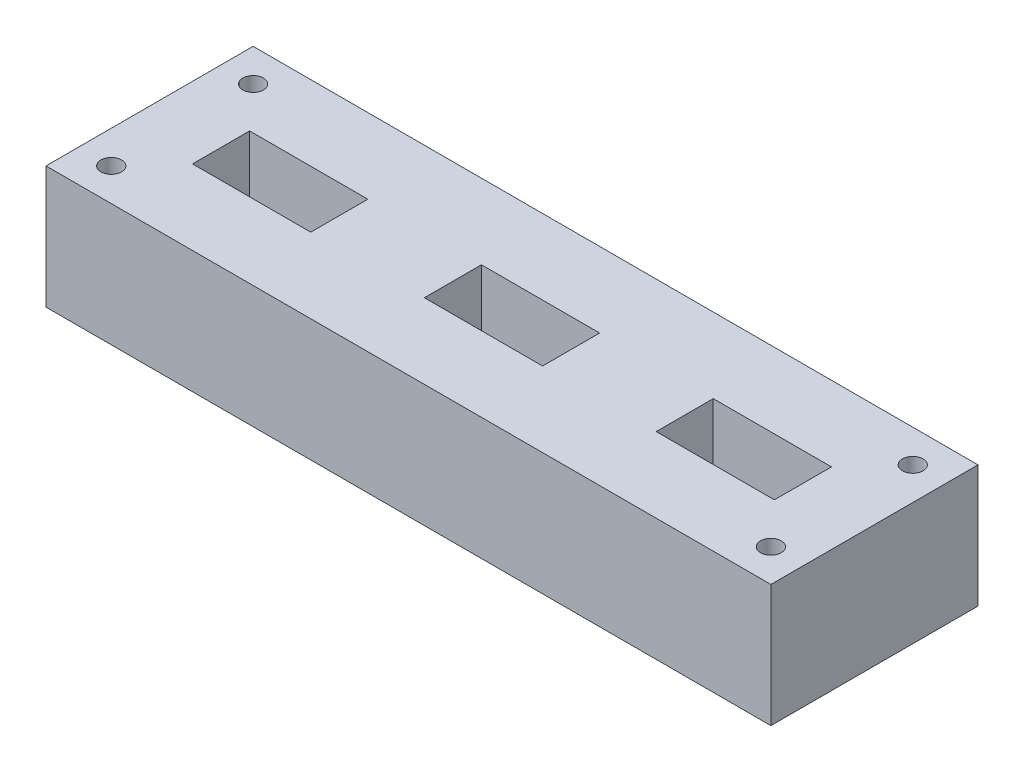
from build123d import *

# Parameters (mm, degrees)
SKETCH1_W           = 88.9
SKETCH1_H           = 25.4
BOSS_EXTRUDE1_DEPTH = 14.999999972
SKETCH2_W           = 14.499999956
SKETCH2_H           = 6.99999997
CUT_EXTRUDE1_DEPTH  = 25.4
SKETCH3_R           = 1.27
CUT_EXTRUDE3_DEPTH  = 25.4


with BuildPart() as part:
    # Sketch1 → Boss-Extrude1 (new body)
    with BuildSketch(Plane(origin=(0, 0, 0), x_dir=(1, 0, 0), z_dir=(0, 1, 0))):
        Rectangle(SKETCH1_W, SKETCH1_H)
    extrude(amount=BOSS_EXTRUDE1_DEPTH)

    # Sketch2 → Cut-Extrude1 (cut)
    with BuildSketch(Plane(origin=(0, 14.999999972, 0), x_dir=(1, 0, 0), z_dir=(0, 1, 0))):
        Rectangle(SKETCH2_W, SKETCH2_H)
        with Locations((-28.430000036, 0)):
            Rectangle(SKETCH2_W, SKETCH2_H)
        with Locations((28.430000036, 0)):
            Rectangle(SKETCH2_W, SKETCH2_H)
    extrude(amount=-CUT_EXTRUDE1_DEPTH, mode=Mode.SUBTRACT)

    # Sketch3 → Cut-Extrude3 (cut)
    with BuildSketch(Plane(origin=(0, 14.999999972, 0), x_dir=(1, 0, 0), z_dir=(0, 1, 0))):
        with Locations((-40.45, 8.7)):
            Circle(SKETCH3_R)
        with Locations((40.45, 8.7)):
            Circle(SKETCH3_R)
        with Locations((-40.45, -8.7)):
            Circle(SKETCH3_R)
        with Locations((40.45, -8.7)):
            Circle(SKETCH3_R)
    extrude(amount=-CUT_EXTRUDE3_DEPTH, mode=Mode.SUBTRACT)


solid = part.part
